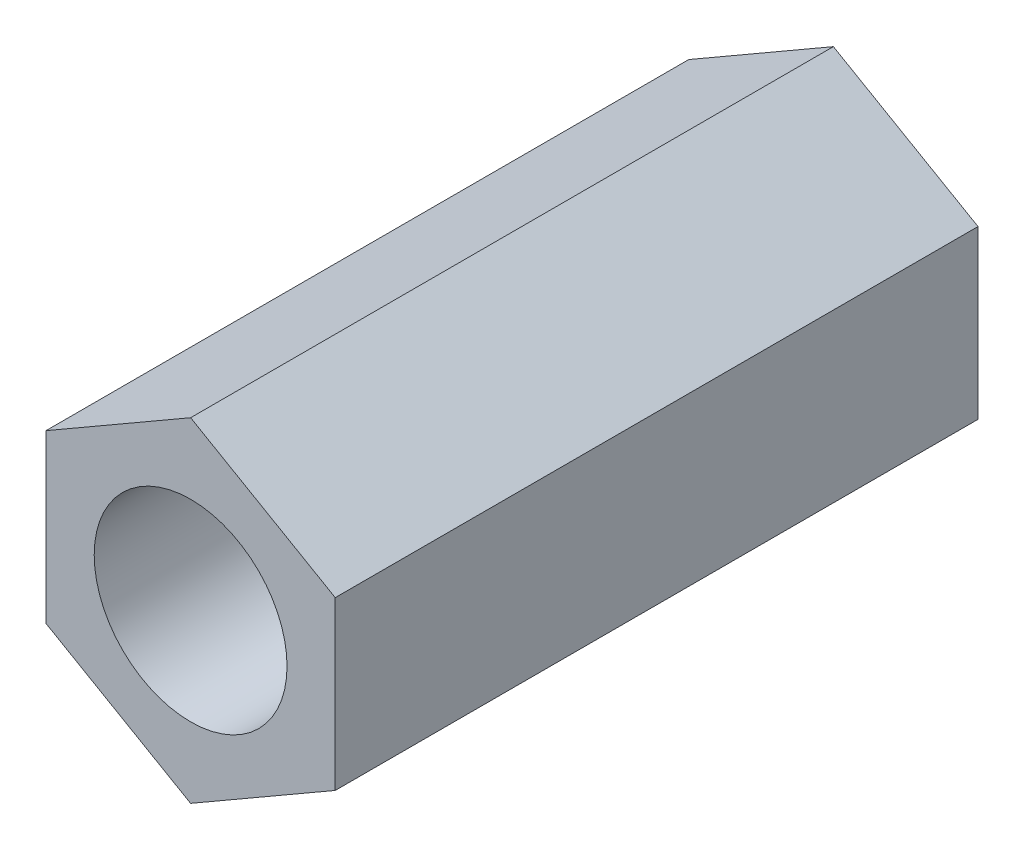
from build123d import *

# Parameters (mm, degrees)
SKETCH1_R           = 1.5
EXTRUDE1_DEPTH      = 5
EXTRUDE1_DEPTH_BACK = 5


with BuildPart() as part:
    # Sketch1 → Extrude1 (new body, two sides)
    with BuildSketch(Plane.XY) as extrude1_sk:
        Polygon((0, 2.598076211), (-2.25, 1.299038106), (-2.25, -1.299038106), (0, -2.598076211), (2.25, -1.299038106), (2.25, 1.299038106), align=None)
        Circle(SKETCH1_R, mode=Mode.SUBTRACT)
    extrude(amount=EXTRUDE1_DEPTH)
    extrude(extrude1_sk.sketch, amount=-EXTRUDE1_DEPTH_BACK)


solid = part.part
